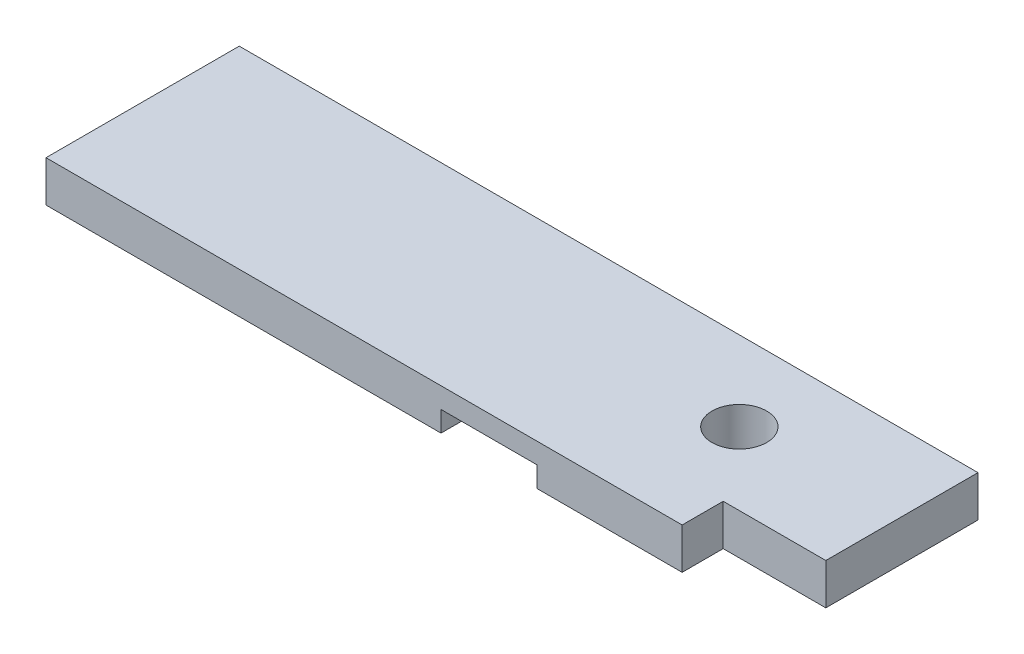
from build123d import *

# Parameters (mm, degrees)
SKETCH1_R           = 25.4
BOSS_EXTRUDE1_DEPTH = 38.1
SKETCH2_W           = 88.9
SKETCH2_H           = 179.4002
CUT_EXTRUDE1_DEPTH  = 19.05


with BuildPart() as part:
    # Sketch1 → Boss-Extrude1 (new body)
    with BuildSketch(Plane(origin=(0, 0, 0), x_dir=(1, 0, 0), z_dir=(0, 1, 0))):
        Polygon((685.8127, 0), (0, 0), (0, -179.4002), (590.5627, -179.4002), (590.5627, -141.2875), (685.8127, -141.2875), align=None)
        with Locations((538.1752, -73.918191)):
            Circle(SKETCH1_R, mode=Mode.SUBTRACT)
    extrude(amount=BOSS_EXTRUDE1_DEPTH)

    # Sketch2 → Cut-Extrude1 (cut)
    with BuildSketch(Plane.XZ):
        with Locations((411.15104079, 89.7001)):
            Rectangle(SKETCH2_W, SKETCH2_H)
    extrude(amount=-CUT_EXTRUDE1_DEPTH, mode=Mode.SUBTRACT)


solid = part.part
